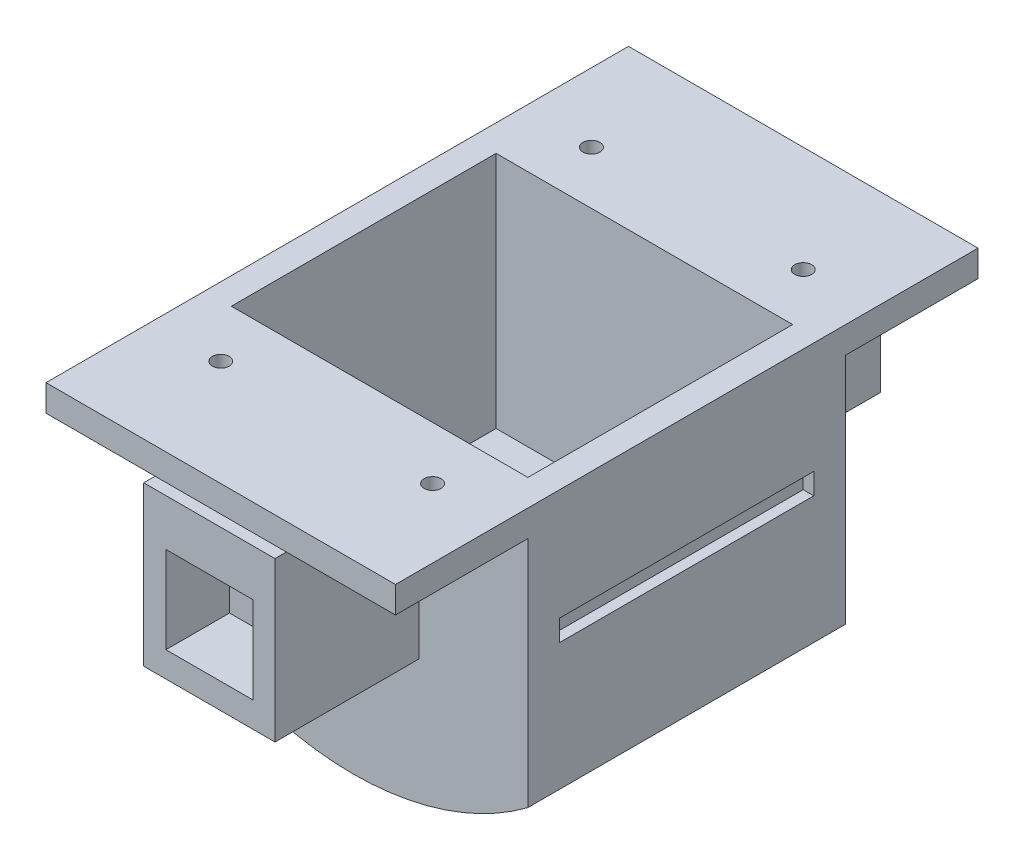
from build123d import *

# Parameters (mm, degrees)
BOSS_EXTRUDE1_DEPTH      = 30
BOSS_EXTRUDE1_DEPTH_BACK = 30
CUT_EXTRUDE1_DEPTH       = 18
CUT_EXTRUDE1_DEPTH_BACK  = 18
SKETCH2_W                = 19
SKETCH2_H                = 52
SKETCH3_W                = 21.854352608
SKETCH3_H                = 45
CUT_EXTRUDE2_DEPTH       = 99.234413522
SKETCH4_R                = 1.6
CUT_EXTRUDE3_DEPTH       = 84.366660003
SKETCH6_W                = 48
SKETCH6_H                = 4
CUT_EXTRUDE5_DEPTH       = 2
SKETCH9_W                = 22
SKETCH9_H                = 60
CUT_EXTRUDE7_DEPTH       = 84.366660003
SKETCH10_W               = 66
SKETCH10_H               = 110
SKETCH10_W_2             = 19
SKETCH10_H_2             = 36
BOSS_EXTRUDE2_DEPTH      = 5
SKETCH11_R               = 1.6
CUT_EXTRUDE8_DEPTH       = 88.82938005
SKETCH13_W               = 24.8
SKETCH13_H               = 30
BOSS_EXTRUDE3_DEPTH      = 27.15
SKETCH14_W               = 16.4
SKETCH14_H               = 16.4
CUT_EXTRUDE9_DEPTH       = 12
SKETCH15_W               = 56
SKETCH15_H               = 50
CUT_EXTRUDE10_DEPTH      = 45


with BuildPart() as part:
    # Sketch1 → Boss-Extrude1 (new, two sides: drawn at the far end of the back side and taken through both)
    with BuildSketch(Plane.XY.offset(-BOSS_EXTRUDE1_DEPTH_BACK)):
        with BuildLine():
            Line((55, 0), (0, 0))
            Line((0, 0), (-55, 0))
            ThreePointArc((-55, 0), (0, -55), (55, 0))
        make_face()
    extrude(amount=BOSS_EXTRUDE1_DEPTH + BOSS_EXTRUDE1_DEPTH_BACK)

    # Sketch2 → Cut-Extrude1 (cut, two sides: drawn at the far end of the back side and taken through both)
    with BuildSketch(Plane.XY.offset(-CUT_EXTRUDE1_DEPTH_BACK)):
        with Locations((0, -26)):
            Rectangle(SKETCH2_W, SKETCH2_H)
    extrude(amount=CUT_EXTRUDE1_DEPTH + CUT_EXTRUDE1_DEPTH_BACK, mode=Mode.SUBTRACT)

    # Sketch3 → Cut-Extrude2 (cut, through all)
    with BuildSketch(Plane.XY.offset(30)):
        with Locations((-43.927176304, -26.5)):
            Rectangle(SKETCH3_W, SKETCH3_H)
        with Locations((43.927176304, -26.5)):
            Rectangle(SKETCH3_W, SKETCH3_H)
    extrude(amount=-CUT_EXTRUDE2_DEPTH, mode=Mode.SUBTRACT)

    # Sketch4 → Cut-Extrude3 (cut, through all)
    with BuildSketch(Plane(origin=(0, 0, 0), x_dir=(1, 0, 0), z_dir=(0, 1, 0))):
        with Locations((45, 20)):
            Circle(SKETCH4_R)
        with Locations((45, -20)):
            Circle(SKETCH4_R)
        with Locations((-45, -20)):
            Circle(SKETCH4_R)
        with Locations((-45, 20)):
            Circle(SKETCH4_R)
    extrude(amount=-CUT_EXTRUDE3_DEPTH, mode=Mode.SUBTRACT)

    # Sketch6 → Cut-Extrude5 (cut)
    with BuildSketch(Plane(origin=(33, 0, 0), x_dir=(0, 0, -1), z_dir=(1, 0, 0))):
        with Locations((0, -18)):
            Rectangle(SKETCH6_W, SKETCH6_H)
    extrude(amount=-CUT_EXTRUDE5_DEPTH, mode=Mode.SUBTRACT)

    # Sketch9 → Cut-Extrude7 (cut, through all)
    with BuildSketch(Plane(origin=(0, 0, 0), x_dir=(1, 0, 0), z_dir=(0, 1, 0))):
        with Locations((-44, 0)):
            Rectangle(SKETCH9_W, SKETCH9_H)
        with Locations((44, 0)):
            Rectangle(SKETCH9_W, SKETCH9_H)
    extrude(amount=-CUT_EXTRUDE7_DEPTH, mode=Mode.SUBTRACT)

    # Sketch10 → Boss-Extrude2 (add)
    with BuildSketch(Plane(origin=(0, 0, 0), x_dir=(1, 0, 0), z_dir=(0, 1, 0))):
        Rectangle(SKETCH10_W, SKETCH10_H)
        Rectangle(SKETCH10_W_2, SKETCH10_H_2, mode=Mode.SUBTRACT)
    extrude(amount=BOSS_EXTRUDE2_DEPTH)

    # Sketch11 → Cut-Extrude8 (cut, through all)
    with BuildSketch(Plane(origin=(0, 5, 0), x_dir=(1, 0, 0), z_dir=(0, 1, 0))):
        with Locations((-20, 35)):
            Circle(SKETCH11_R)
        with Locations((20, 35)):
            Circle(SKETCH11_R)
        with Locations((-20, -35)):
            Circle(SKETCH11_R)
        with Locations((20, -35)):
            Circle(SKETCH11_R)
    extrude(amount=-CUT_EXTRUDE8_DEPTH, mode=Mode.SUBTRACT)

    # Sketch13 → Boss-Extrude3 (add)
    with BuildSketch(Plane(origin=(0, 0, -30), x_dir=(-1, 0, 0), z_dir=(0, 0, -1))):
        with Locations((0, -15)):
            Rectangle(SKETCH13_W, SKETCH13_H)
    boss_extrude3 = extrude(amount=BOSS_EXTRUDE3_DEPTH)

    # Sketch14 → Cut-Extrude9 (cut)
    with BuildSketch(Plane(origin=(0, 0, -57.15), x_dir=(-1, 0, 0), z_dir=(0, 0, -1))):
        with Locations((0, -17)):
            Rectangle(SKETCH14_W, SKETCH14_H)
    cut_extrude9 = extrude(amount=-CUT_EXTRUDE9_DEPTH, mode=Mode.SUBTRACT)

    # Mirror2: Boss-Extrude3 across plane
    add(boss_extrude3.mirror(Plane(origin=(0, 0, 0), x_dir=(1, 0, 0), z_dir=(0, 0, -1))))

    # Mirror3: Cut-Extrude9 across plane
    add(cut_extrude9.mirror(Plane(origin=(0, 0, 0), x_dir=(1, 0, 0), z_dir=(0, 0, -1))), mode=Mode.SUBTRACT)

    # Sketch15 → Cut-Extrude10 (cut)
    with BuildSketch(Plane(origin=(0, 5, 0), x_dir=(1, 0, 0), z_dir=(0, 1, 0))):
        Rectangle(SKETCH15_W, SKETCH15_H)
    extrude(amount=-CUT_EXTRUDE10_DEPTH, mode=Mode.SUBTRACT)


solid = part.part
